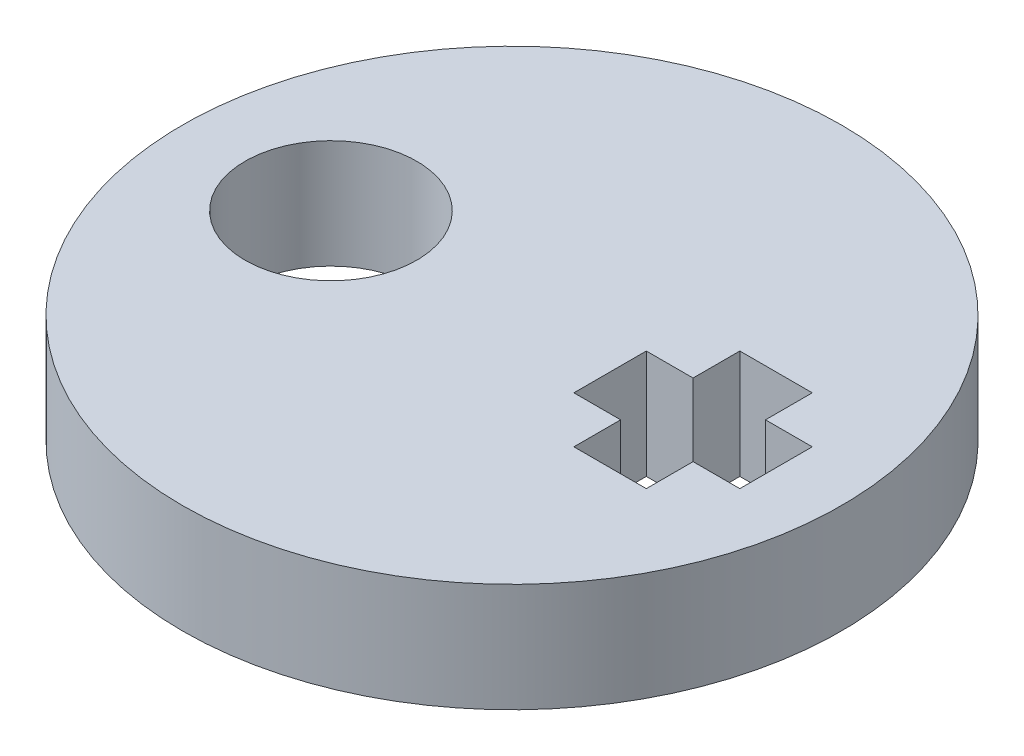
from build123d import *

# Parameters (mm, degrees)
SKETCH1_R           = 9.1
SKETCH1_R_2         = 2.37
BOSS_EXTRUDE1_DEPTH = 3


with BuildPart() as part:
    # Sketch1 → Boss-Extrude1 (new body)
    with BuildSketch(Plane(origin=(0, 0, 0), x_dir=(1, 0, 0), z_dir=(0, 1, 0))):
        Circle(SKETCH1_R)
        with Locations((-5, 0)):
            Circle(SKETCH1_R_2, mode=Mode.SUBTRACT)
        Polygon((7.291287847, -1), (6, -1), (6, -2.291287847), (4, -2.291287847), (4, -1), (2.708712153, -1), (2.708712153, 1), (4, 1), (4, 2.291287847), (6, 2.291287847), (6, 1), (7.291287847, 1), align=None, mode=Mode.SUBTRACT)
    extrude(amount=BOSS_EXTRUDE1_DEPTH)


solid = part.part
